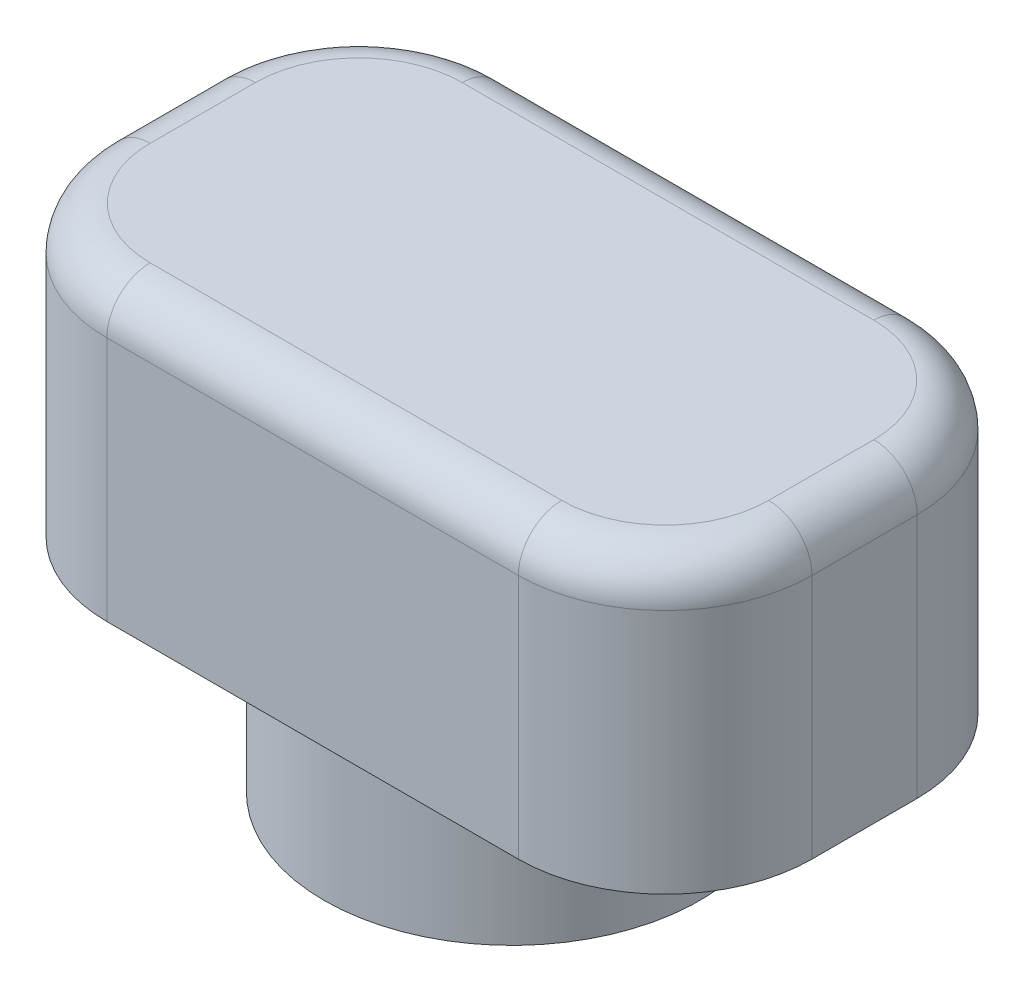
from build123d import *

# Parameters (mm, degrees)
SKETCH1_R           = 3.25
BOSS_EXTRUDE1_DEPTH = 2.5
SKETCH2_R           = 1.75
CUT_EXTRUDE1_DEPTH  = 2.5
SKETCH3_W           = 12.2
SKETCH3_H           = 6.9
BOSS_EXTRUDE2_DEPTH = 5
FILLET1_R           = 2.54
FILLET2_R           = 0.75


with BuildPart() as part:
    # Sketch1 → Boss-Extrude1 (new body)
    with BuildSketch(Plane(origin=(0, 0, 0), x_dir=(1, 0, 0), z_dir=(0, 1, 0))):
        Circle(SKETCH1_R)
    extrude(amount=BOSS_EXTRUDE1_DEPTH)

    # Sketch2 → Cut-Extrude1 (cut)
    with BuildSketch(Plane.XZ):
        Circle(SKETCH2_R)
    extrude(amount=-CUT_EXTRUDE1_DEPTH, mode=Mode.SUBTRACT)

    # Sketch3 → Boss-Extrude2 (add)
    with BuildSketch(Plane(origin=(0, 2.5, 0), x_dir=(1, 0, 0), z_dir=(0, 1, 0))):
        Rectangle(SKETCH3_W, SKETCH3_H)
    extrude(amount=BOSS_EXTRUDE2_DEPTH)

    # Fillet1
    fillet1_edges = [part.edges().sort_by_distance(p)[0] for p in [
        (6.1, 5, 3.45),
        (6.1, 5, -3.45),
        (-6.1, 5, -3.45),
        (-6.1, 5, 3.45),
    ]]
    fillet(fillet1_edges, radius=FILLET1_R)

    # Fillet2
    fillet2_edges = [part.edges().sort_by_distance(p)[0] for p in [
        (-6.1, 7.5, 0),
        (0, 7.5, -3.45),
        (6.1, 7.5, 0),
        (0, 7.5, 3.45),
        (-5.356051224, 7.5, 2.706051224),
        (5.356051224, 7.5, 2.706051224),
        (5.356051224, 7.5, -2.706051224),
        (-5.356051224, 7.5, -2.706051224),
    ]]
    fillet(fillet2_edges, radius=FILLET2_R)


solid = part.part
